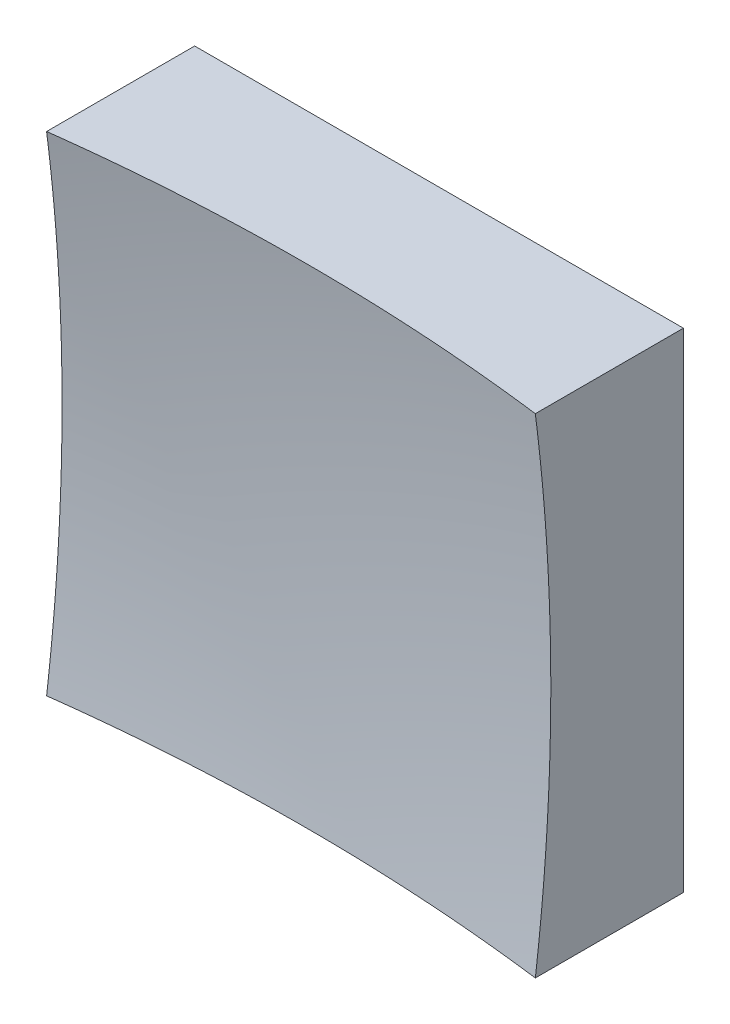
from build123d import *

# Parameters (mm, degrees)
SKETCH_1_W      = 12.5
SKETCH_1_H      = 12.5
EXTRUDE_1_DEPTH = 10


with BuildPart() as part:
    # 草图1 → 凸台-拉伸1 (new body)
    with BuildSketch(Plane.XY):
        Rectangle(SKETCH_1_W, SKETCH_1_H)
    extrude(amount=EXTRUDE_1_DEPTH)

    # 草图2 → 切除-旋转2 (revolve, cut)
    with BuildSketch(Plane(origin=(0, 0, 0), x_dir=(1, 0, 0), z_dir=(0, 1, 0))):
        with BuildLine():
            Line((48.742273091, -41.855906768), (0, -41.855906768))
            Line((0, -41.855906768), (0, -3))
            ThreePointArc((0, -3), (31.167253155, -13.902655707), (48.742273091, -41.855906768))
        make_face()
    revolve(axis=Axis((0, 0, 41.855906768), (0, 0, -1)), mode=Mode.SUBTRACT)


solid = part.part
